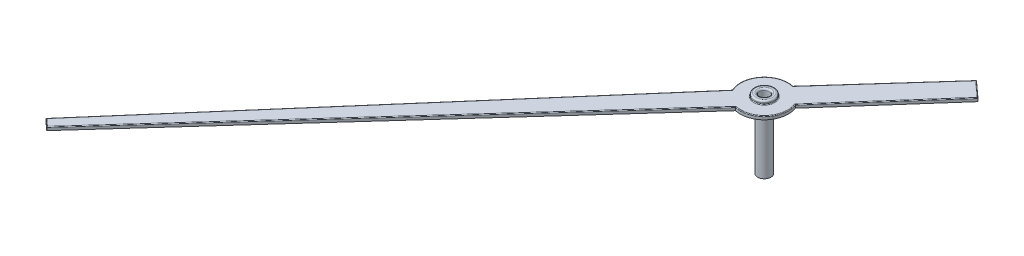
from build123d import *

# Parameters (mm, degrees)
SKETCH1_R                = 0.15
BOSS_EXTRUDE1_DEPTH      = 0.1
SKETCH2_R                = 0.3
SKETCH2_R_2              = 0.15
BOSS_EXTRUDE2_DEPTH      = 0.1
BOSS_EXTRUDE2_DEPTH_BACK = 2
FILLET1_R                = 0.05
FILLET2_R                = 0.02
SKETCH3_R                = 0.431407551
SKETCH3_R_2              = 0.2
CUT_EXTRUDE1_DEPTH       = 1.9


with BuildPart() as part:
    # Sketch1 → Boss-Extrude1 (new body)
    with BuildSketch(Plane(origin=(0, 0, 0), x_dir=(1, 0, 0), z_dir=(0, 1, 0))):
        with BuildLine():
            Line((-82.406253285, -49.725868429), (-72.592962822, -38.875374501))
            ThreePointArc((-72.592962822, -38.875374501), (-71.888648973, -38.644732606), (-71.760288486, -37.914816674))
            Line((-71.760288486, -37.914816674), (-69.191054527, -35.004040233))
            Line((-69.191054527, -35.004040233), (-69.671325788, -34.569459042))
            Line((-69.671325788, -34.569459042), (-72.275341711, -37.469639173))
            ThreePointArc((-72.275341711, -37.469639173), (-72.996004438, -37.722822834), (-73.084190733, -38.481558565))
            Line((-73.084190733, -38.481558565), (-82.643859616, -49.510974991))
            Line((-82.643859616, -49.510974991), (-82.406253285, -49.725868429))
        make_face()
        with Locations((-72.433134731, -38.172736745)):
            Circle(SKETCH1_R, mode=Mode.SUBTRACT)
    extrude(amount=BOSS_EXTRUDE1_DEPTH)

    # Sketch2 → Boss-Extrude2 (add, two sides)
    with BuildSketch(Plane(origin=(0, 0.1, 0), x_dir=(1, 0, 0), z_dir=(0, 1, 0))) as boss_extrude2_sk:
        with Locations((-72.433134731, -38.172736745)):
            Circle(SKETCH2_R)
        with Locations((-72.433134731, -38.172736745)):
            Circle(SKETCH2_R_2, mode=Mode.SUBTRACT)
    extrude(amount=BOSS_EXTRUDE2_DEPTH)
    extrude(boss_extrude2_sk.sketch, amount=-BOSS_EXTRUDE2_DEPTH_BACK)

    # Fillet1
    fillet1_edges = [part.edges().sort_by_distance(p)[0] for p in [
        (-72.583134731, 0.2, 38.172736745),
        (-72.733134731, 0.2, 38.172736745),
    ]]
    fillet(fillet1_edges, radius=FILLET1_R)

    # Fillet2
    fillet2_edges = [part.edges().sort_by_distance(p)[0] for p in [
        (-77.499608053, 0.1, 44.300621465),
        (-71.888648973, 0.1, 38.644732606),
        (-70.475671506, 0.1, 36.459428453),
        (-69.431190157, 0.1, 34.786749638),
        (-70.973333749, 0.1, 36.019549108),
        (-72.733134731, 0.1, 38.172736745),
        (-72.996004438, 0.1, 37.722822834),
        (-77.864025175, 0.1, 43.996266778),
        (-82.52505645, 0.1, 49.61842171),
    ]]
    fillet(fillet2_edges, radius=FILLET2_R)

    # Sketch3 → Cut-Extrude1 (cut)
    with BuildSketch(Plane.XZ.offset(1.9)):
        with Locations((-72.433134731, 38.172736745)):
            Circle(SKETCH3_R)
        with Locations((-72.433134731, 38.172736745)):
            Circle(SKETCH3_R_2, mode=Mode.SUBTRACT)
    extrude(amount=-CUT_EXTRUDE1_DEPTH, mode=Mode.SUBTRACT)


solid = part.part
